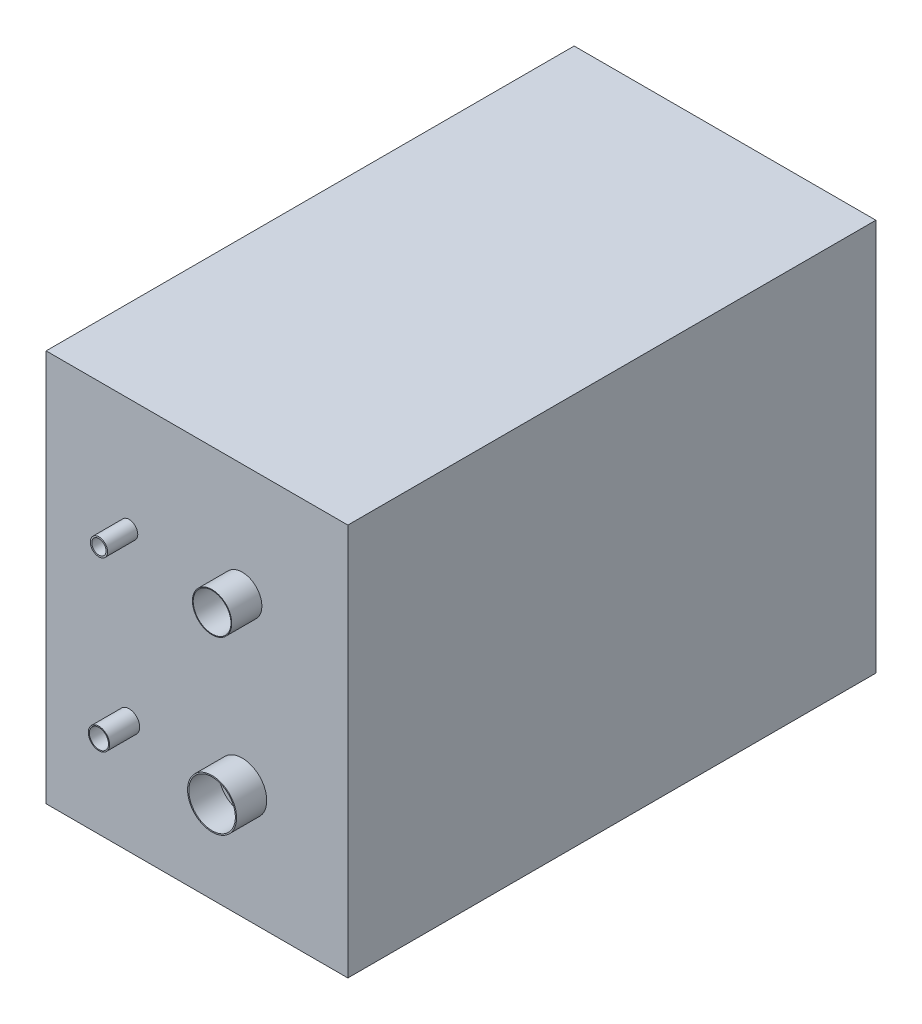
from build123d import *

# Parameters (mm, degrees)
SKETCH1_W      = 2000
SKETCH1_H      = 2600
EXTRUDE1_DEPTH = 3500
SKETCH2_R      = 162.5
SKETCH2_R_2    = 154.5
SKETCH2_R_3    = 70.5
SKETCH2_R_4    = 63.5
SKETCH2_R_5    = 130
SKETCH2_R_6    = 125
SKETCH2_R_7    = 57.5
SKETCH2_R_8    = 47.5
EXTRUDE2_DEPTH = 200


with BuildPart() as part:
    # Sketch1 → Extrude1 (new body)
    with BuildSketch(Plane.XY):
        with Locations((-2900, 3871.506535609)):
            Rectangle(SKETCH1_W, SKETCH1_H)
    extrude(amount=EXTRUDE1_DEPTH)

    # Sketch2 → Extrude2 (add)
    with BuildSketch(Plane.XY.offset(3500)):
        with Locations((-2600, 3321.506535609)):
            Circle(SKETCH2_R)
        with Locations((-2600, 3321.506535609)):
            Circle(SKETCH2_R_2, mode=Mode.SUBTRACT)
        with Locations((-3350, 3321.506535609)):
            Circle(SKETCH2_R_3)
        with Locations((-3350, 3321.506535609)):
            Circle(SKETCH2_R_4, mode=Mode.SUBTRACT)
        with Locations((-2600, 4421.506535609)):
            Circle(SKETCH2_R_5)
        with Locations((-2600, 4421.506535609)):
            Circle(SKETCH2_R_6, mode=Mode.SUBTRACT)
        with Locations((-3350, 4421.506535609)):
            Circle(SKETCH2_R_7)
        with Locations((-3350, 4421.506535609)):
            Circle(SKETCH2_R_8, mode=Mode.SUBTRACT)
    extrude(amount=EXTRUDE2_DEPTH)


solid = part.part
